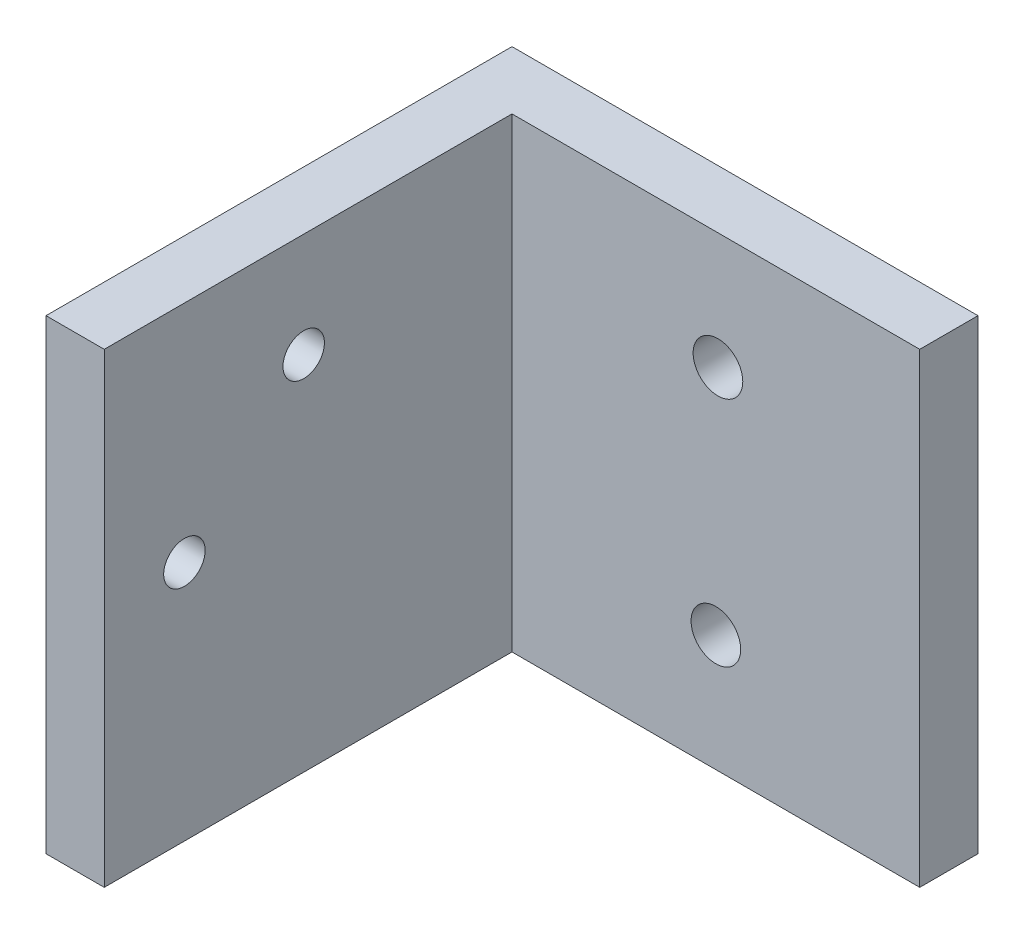
from build123d import *

# Parameters (mm, degrees)
BOSS_EXTRUDE2_DEPTH           = 25.4
TAP_DRILL_FOR_4_40_TAP1_D     = 2.2606
TAP_DRILL_FOR_4_40_TAP1_DEPTH = 3.302
TAP_DRILL_FOR_4_40_TAP1_TIP   = 0.679152758
TAP_DRILL_FOR_6_32_TAP1_D     = 2.7051
TAP_DRILL_FOR_6_32_TAP1_DEPTH = 3.302
TAP_DRILL_FOR_6_32_TAP1_TIP   = 0.81269403


with BuildPart() as part:
    # Sketch1 → Boss-Extrude2 (new body)
    with BuildSketch(Plane(origin=(0, 0, 0), x_dir=(1, 0, 0), z_dir=(0, 1, 0))):
        Polygon((-35.951603547, -27.391556999), (-32.776603547, -27.391556999), (-32.776603547, -5.166556999), (-10.551603547, -5.166556999), (-10.551603547, -1.991556999), (-35.951603547, -1.991556999), align=None)
    extrude(amount=BOSS_EXTRUDE2_DEPTH)

    # Tap Drill for #4-40 Tap1
    with Locations(Plane.ZY.offset(35.951603547)):
        with Locations((16.520356999, 19.7104), (23.022756999, 13.1572)):
            Hole(TAP_DRILL_FOR_4_40_TAP1_D / 2, depth=TAP_DRILL_FOR_4_40_TAP1_DEPTH)
            with Locations((0, 0, -(TAP_DRILL_FOR_4_40_TAP1_DEPTH + TAP_DRILL_FOR_4_40_TAP1_TIP / 2))):  # 118° drill point
                Cone(0, TAP_DRILL_FOR_4_40_TAP1_D / 2, TAP_DRILL_FOR_4_40_TAP1_TIP, mode=Mode.SUBTRACT)

    # Tap Drill for #6-32 Tap1
    with Locations(Plane(origin=(-21.664103547, 6.35, 5.166556999), x_dir=(1, 0, 0), z_dir=(0, 0, 1))):
        with Locations((0, 0), (0.113463967, 12.7)):
            Hole(TAP_DRILL_FOR_6_32_TAP1_D / 2, depth=TAP_DRILL_FOR_6_32_TAP1_DEPTH)
            with Locations((0, 0, -(TAP_DRILL_FOR_6_32_TAP1_DEPTH + TAP_DRILL_FOR_6_32_TAP1_TIP / 2))):  # 118° drill point
                Cone(0, TAP_DRILL_FOR_6_32_TAP1_D / 2, TAP_DRILL_FOR_6_32_TAP1_TIP, mode=Mode.SUBTRACT)


solid = part.part
